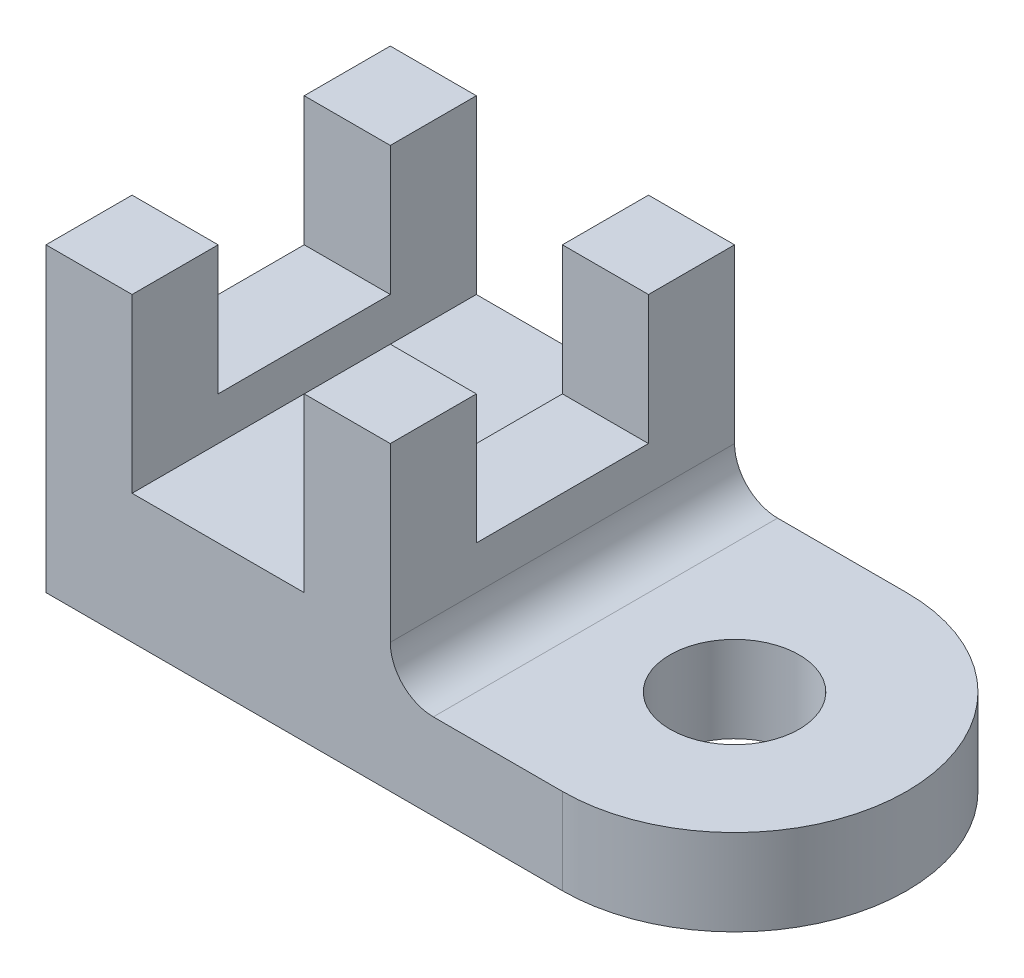
from build123d import *

# Parameters (mm, degrees)
BASEEXTRUDE_DEPTH           = 25.4
SKETCH2_R                   = 25.4
BOSS_EXTRUDE2_DEPTH         = 12.7
F_3_4_0_75_DIAMETER_HOLE2_D = 19.05
SKETCH9_W                   = 25.4
SKETCH9_H                   = 19.05
CUT_EXTRUDE1_DEPTH          = 51.8


with BuildPart() as part:
    # base → baseExtrude (new body, symmetric)
    with BuildSketch(Plane.XY):
        with BuildLine():
            Line((-38.1, 0), (38.1, 0))
            Line((38.1, 0), (38.1, 12.7))
            Line((38.1, 12.7), (19.05, 12.7))
            ThreePointArc((19.05, 12.7), (14.559871939, 14.559871939), (12.7, 19.05))
            Line((12.7, 19.05), (12.7, 44.45))
            Line((12.7, 44.45), (0, 44.45))
            Line((0, 44.45), (0, 19.05))
            Line((0, 19.05), (-25.4, 19.05))
            Line((-25.4, 19.05), (-25.4, 44.45))
            Line((-25.4, 44.45), (-38.1, 44.45))
            Line((-38.1, 44.45), (-38.1, 0))
        make_face()
    extrude(amount=BASEEXTRUDE_DEPTH, both=True)

    # Sketch2 → Boss-Extrude2 (add)
    with BuildSketch(Plane.XZ):
        with Locations((38.1, 0)):
            Circle(SKETCH2_R)
    extrude(amount=-BOSS_EXTRUDE2_DEPTH)

    # 3/4 (0.75) Diameter Hole2 (through all)
    with Locations(Plane(origin=(0, 12.7, 0), x_dir=(1, 0, 0), z_dir=(0, 1, 0))):
        with Locations((38.1, 0)):
            Hole(F_3_4_0_75_DIAMETER_HOLE2_D / 2)

    # Sketch9 → Cut-Extrude1 (cut, through all)
    with BuildSketch(Plane(origin=(12.7, 0, 0), x_dir=(0, 0, -1), z_dir=(1, 0, 0))):
        with Locations((0, 34.925)):
            Rectangle(SKETCH9_W, SKETCH9_H)
    extrude(amount=-CUT_EXTRUDE1_DEPTH, mode=Mode.SUBTRACT)


solid = part.part
